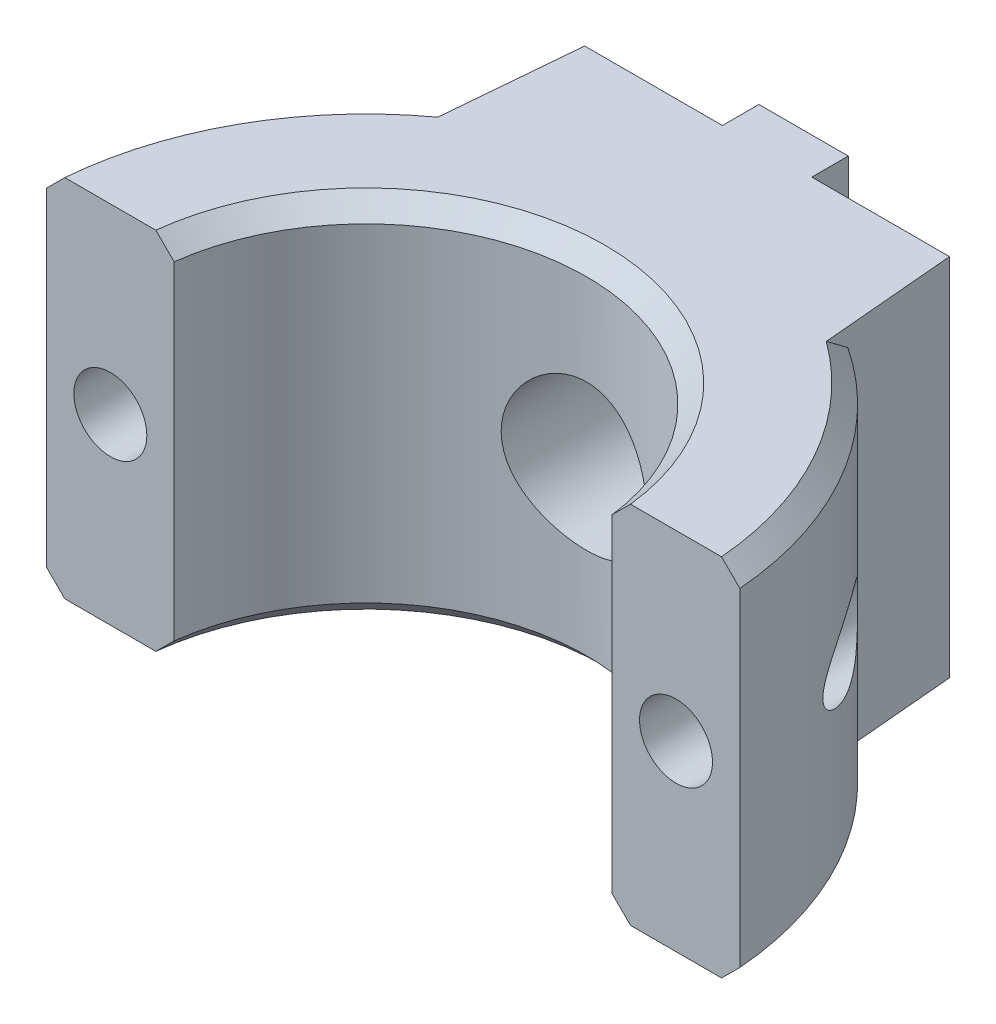
from build123d import *

# Parameters (mm, degrees)
AUFSATZ_LINEAR_AUSTRAGEN1_DEPTH                      = 10
SKIZZE4_W                                            = 4.9
SKIZZE4_H                                            = 20
AUFSATZ_LINEAR_AUSTRAGEN2_DEPTH                      = 2
STIRNSENKUNG_F_R_M4_ZYLINDERSCHRAUBE_MIT_D           = 4.5
STIRNSENKUNG_F_R_M4_ZYLINDERSCHRAUBE_MIT_CBORE_D     = 8
STIRNSENKUNG_F_R_M4_ZYLINDERSCHRAUBE_MIT_CBORE_DEPTH = 16
F_4_0_4_DURCHMESSER_BOHRUNG1_D                       = 4
FASE1_SIZE                                           = 1


with BuildPart() as part:
    # Skizze1 → Aufsatz-Linear austragen1 (new body, symmetric)
    with BuildSketch(Plane(origin=(0, 0, 0), x_dir=(1, 0, 0), z_dir=(0, 1, 0))):
        with BuildLine():
            ThreePointArc((-10.534455372, 15.89114714), (-16.430025091, 9.672516887), (-19.006664816, 1.5))
            Line((-19.006664816, 1.5), (-12.006664816, 1.5))
            ThreePointArc((-12.006664816, 1.5), (0, 12.1), (12.006664816, 1.5))
            Line((12.006664816, 1.5), (19.006664816, 1.5))
            ThreePointArc((19.006664816, 1.5), (16.430025091, 9.672516887), (10.534455372, 15.89114714))
            Line((10.534455372, 15.89114714), (10, 22))
            Line((10, 22), (-10, 22))
            Line((-10, 22), (-10.534455372, 15.89114714))
        make_face()
    extrude(amount=AUFSATZ_LINEAR_AUSTRAGEN1_DEPTH, both=True)

    # Skizze4 → Aufsatz-Linear austragen2 (add)
    with BuildSketch(Plane(origin=(0, 0, -22), x_dir=(-1, 0, 0), z_dir=(0, 0, -1))):
        Rectangle(SKIZZE4_W, SKIZZE4_H)
    extrude(amount=AUFSATZ_LINEAR_AUSTRAGEN2_DEPTH)

    # Stirnsenkung für M4 Zylinderschraube mit Innensechskant1 (through all)
    with Locations(Plane.XY.offset(-1.5)):
        with Locations((0, 0)):
            CounterBoreHole(STIRNSENKUNG_F_R_M4_ZYLINDERSCHRAUBE_MIT_D / 2, STIRNSENKUNG_F_R_M4_ZYLINDERSCHRAUBE_MIT_CBORE_D / 2, STIRNSENKUNG_F_R_M4_ZYLINDERSCHRAUBE_MIT_CBORE_DEPTH)

    # Ø4.0 (4) Durchmesser Bohrung1 (through all)
    with Locations(Plane.XY.offset(-1.5)):
        with Locations((-15.506664816, 0), (15.506664816, 0)):
            Hole(F_4_0_4_DURCHMESSER_BOHRUNG1_D / 2)

    # Fase1
    fase1_edges = [part.edges().sort_by_distance(p)[0] for p in [
        (0, -10, -12.1),
        (-16.430025091, -10, -9.672516887),
        (16.430025091, -10, -9.672516887),
        (-16.430025091, 10, -9.672516887),
        (0, 10, -12.1),
        (16.430025091, 10, -9.672516887),
    ]]
    chamfer(fase1_edges, length=FASE1_SIZE)


solid = part.part
